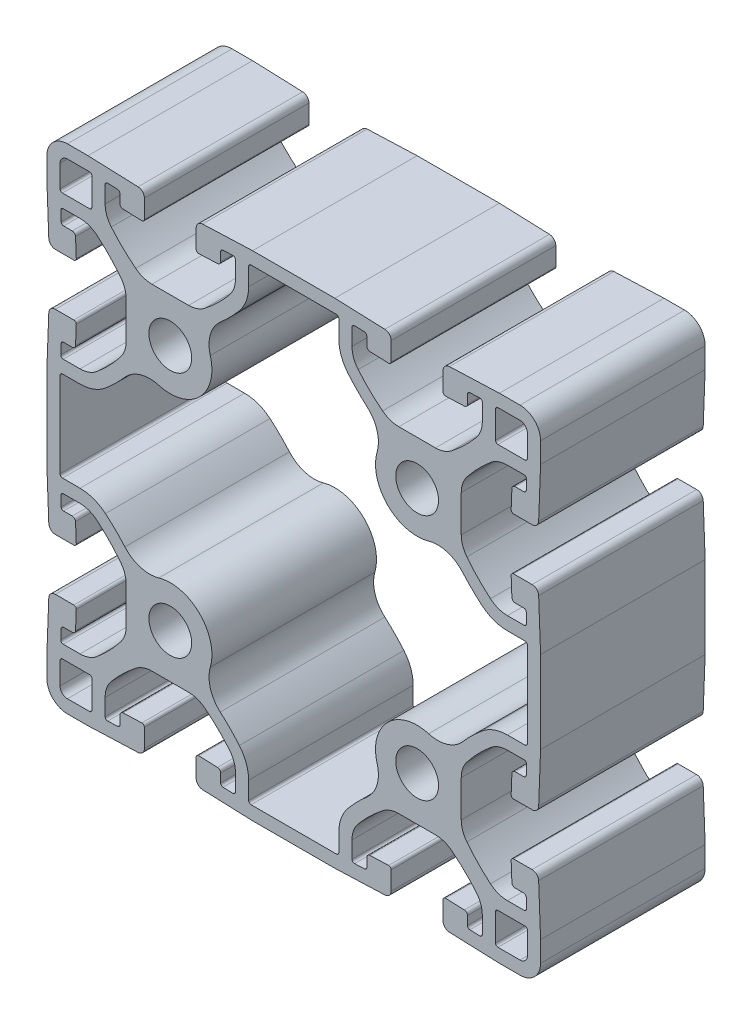
from build123d import *

# Parameters (mm, degrees)
SKETCH1_R      = 3.302
EXTRUDE1_DEPTH = 25.4


with BuildPart() as part:
    # Sketch1 → Extrude1 (new body)
    with BuildSketch(Plane.XY):
        with BuildLine():
            Line((44.9072, 40.928100791), (44.9072, 35.271899209))
            ThreePointArc((44.9072, 35.271899209), (45.129801128, 33.945343253), (45.773219048, 32.764108582))
            ThreePointArc((45.773219048, 32.764108582), (47.497406099, 30.785158596), (49.416608824, 28.994704762))
            ThreePointArc((49.416608824, 28.994704762), (50.63999053, 28.287303636), (52.031647412, 28.0416))
            Line((52.031647412, 28.0416), (54.619103526, 28.0416))
            ThreePointArc((54.619103526, 28.0416), (54.8936335, 28.158413903), (54.999822697, 28.437225755))
            Line((54.999822697, 28.437225755), (54.941276523, 29.961225755))
            ThreePointArc((54.941276523, 29.961225755), (54.824743448, 30.221129974), (54.560557352, 30.3276))
            Line((54.560557352, 30.3276), (53.230049894, 30.3276))
            ThreePointArc((53.230049894, 30.3276), (52.877801765, 30.469560035), (52.722424332, 30.816098993))
            Line((52.722424332, 30.816098993), (52.611487197, 33.703874245))
            ThreePointArc((52.611487197, 33.703874245), (52.717676395, 33.982686097), (52.992206369, 34.0995))
            Line((52.992206369, 34.0995), (55.838080274, 34.0995))
            ThreePointArc((55.838080274, 34.0995), (56.542576532, 33.815579929), (56.853331397, 33.122502014))
            Line((56.853331397, 33.122502014), (57.15, 25.4))
            Line((57.15, 25.4), (57.15, 19.05))
            Line((57.15, 19.05), (57.15, 12.7))
            Line((57.15, 12.7), (56.853331397, 4.977497986))
            ThreePointArc((56.853331397, 4.977497986), (56.542576532, 4.284420071), (55.838080274, 4.0005))
            Line((55.838080274, 4.0005), (52.992206369, 4.0005))
            ThreePointArc((52.992206369, 4.0005), (52.717676395, 4.117313903), (52.611487197, 4.396125755))
            Line((52.611487197, 4.396125755), (52.722424332, 7.283901007))
            ThreePointArc((52.722424332, 7.283901007), (52.877801765, 7.630439965), (53.230049894, 7.7724))
            Line((53.230049894, 7.7724), (54.560557352, 7.7724))
            ThreePointArc((54.560557352, 7.7724), (54.824743448, 7.878870026), (54.941276523, 8.138774245))
            Line((54.941276523, 8.138774245), (54.999822697, 9.662774245))
            ThreePointArc((54.999822697, 9.662774245), (54.8936335, 9.941586097), (54.619103526, 10.0584))
            Line((54.619103526, 10.0584), (52.031647412, 10.0584))
            ThreePointArc((52.031647412, 10.0584), (50.63999053, 9.812696364), (49.416608824, 9.105295238))
            ThreePointArc((49.416608824, 9.105295238), (47.497406099, 7.314841404), (45.773219048, 5.335891418))
            ThreePointArc((45.773219048, 5.335891418), (45.129801128, 4.154656747), (44.9072, 2.828100791))
            Line((44.9072, 2.828100791), (44.9072, -2.828100791))
            ThreePointArc((44.9072, -2.828100791), (45.129801128, -4.154656747), (45.773219048, -5.335891418))
            ThreePointArc((45.773219048, -5.335891418), (47.497406099, -7.314841404), (49.416608824, -9.105295238))
            ThreePointArc((49.416608824, -9.105295238), (50.63999053, -9.812696364), (52.031647412, -10.0584))
            Line((52.031647412, -10.0584), (54.619103526, -10.0584))
            ThreePointArc((54.619103526, -10.0584), (54.8936335, -9.941586097), (54.999822697, -9.662774245))
            Line((54.999822697, -9.662774245), (54.941276523, -8.138774245))
            ThreePointArc((54.941276523, -8.138774245), (54.824743448, -7.878870026), (54.560557352, -7.7724))
            Line((54.560557352, -7.7724), (53.230049894, -7.7724))
            ThreePointArc((53.230049894, -7.7724), (52.877801765, -7.630439965), (52.722424332, -7.283901007))
            Line((52.722424332, -7.283901007), (52.611487197, -4.396125755))
            ThreePointArc((52.611487197, -4.396125755), (52.717676395, -4.117313903), (52.992206369, -4.0005))
            Line((52.992206369, -4.0005), (55.838080274, -4.0005))
            ThreePointArc((55.838080274, -4.0005), (56.542576532, -4.284420071), (56.853331397, -4.977497986))
            Line((56.853331397, -4.977497986), (57.15, -12.7))
            Line((57.15, -12.7), (57.15, -15.875))
            ThreePointArc((57.15, -15.875), (56.22006403, -18.12006403), (53.975, -19.05))
            Line((53.975, -19.05), (50.8, -19.05))
            Line((50.8, -19.05), (43.077497986, -18.753331397))
            ThreePointArc((43.077497986, -18.753331397), (42.384420071, -18.442576532), (42.1005, -17.738080274))
            Line((42.1005, -17.738080274), (42.1005, -14.892206369))
            ThreePointArc((42.1005, -14.892206369), (42.217313903, -14.617676395), (42.496125755, -14.511487197))
            Line((42.496125755, -14.511487197), (45.383901007, -14.622424332))
            ThreePointArc((45.383901007, -14.622424332), (45.730439965, -14.777801765), (45.8724, -15.130049894))
            Line((45.8724, -15.130049894), (45.8724, -16.460557352))
            ThreePointArc((45.8724, -16.460557352), (45.978870026, -16.724743448), (46.238774245, -16.841276523))
            Line((46.238774245, -16.841276523), (47.762774245, -16.899822697))
            ThreePointArc((47.762774245, -16.899822697), (48.041586097, -16.7936335), (48.1584, -16.519103526))
            Line((48.1584, -16.519103526), (48.1584, -13.931647412))
            ThreePointArc((48.1584, -13.931647412), (47.912696364, -12.53999053), (47.205295238, -11.316608824))
            ThreePointArc((47.205295238, -11.316608824), (45.414841404, -9.397406099), (43.435891418, -7.673219048))
            ThreePointArc((43.435891418, -7.673219048), (42.254656747, -7.029801128), (40.928100791, -6.8072))
            Line((40.928100791, -6.8072), (35.271899209, -6.8072))
            ThreePointArc((35.271899209, -6.8072), (33.945343253, -7.029801128), (32.764108582, -7.673219048))
            ThreePointArc((32.764108582, -7.673219048), (30.785158596, -9.397406099), (28.994704762, -11.316608824))
            ThreePointArc((28.994704762, -11.316608824), (28.287303636, -12.53999053), (28.0416, -13.931647412))
            Line((28.0416, -13.931647412), (28.0416, -16.519103526))
            ThreePointArc((28.0416, -16.519103526), (28.158413903, -16.7936335), (28.437225755, -16.899822697))
            Line((28.437225755, -16.899822697), (29.961225755, -16.841276523))
            ThreePointArc((29.961225755, -16.841276523), (30.221129974, -16.724743448), (30.3276, -16.460557352))
            Line((30.3276, -16.460557352), (30.3276, -15.130049894))
            ThreePointArc((30.3276, -15.130049894), (30.469560035, -14.777801765), (30.816098993, -14.622424332))
            Line((30.816098993, -14.622424332), (33.703874245, -14.511487197))
            ThreePointArc((33.703874245, -14.511487197), (33.982686097, -14.617676395), (34.0995, -14.892206369))
            Line((34.0995, -14.892206369), (34.0995, -17.738080274))
            ThreePointArc((34.0995, -17.738080274), (33.815579929, -18.442576532), (33.122502014, -18.753331397))
            Line((33.122502014, -18.753331397), (25.4, -19.05))
            Line((25.4, -19.05), (19.05, -19.05))
            Line((19.05, -19.05), (12.7, -19.05))
            Line((12.7, -19.05), (4.977497986, -18.753331397))
            ThreePointArc((4.977497986, -18.753331397), (4.284420071, -18.442576532), (4.0005, -17.738080274))
            Line((4.0005, -17.738080274), (4.0005, -14.892206369))
            ThreePointArc((4.0005, -14.892206369), (4.117313903, -14.617676395), (4.396125755, -14.511487197))
            Line((4.396125755, -14.511487197), (7.283901007, -14.622424332))
            ThreePointArc((7.283901007, -14.622424332), (7.630439965, -14.777801765), (7.7724, -15.130049894))
            Line((7.7724, -15.130049894), (7.7724, -16.460557352))
            ThreePointArc((7.7724, -16.460557352), (7.878870026, -16.724743448), (8.138774245, -16.841276523))
            Line((8.138774245, -16.841276523), (9.662774245, -16.899822697))
            ThreePointArc((9.662774245, -16.899822697), (9.941586097, -16.7936335), (10.0584, -16.519103526))
            Line((10.0584, -16.519103526), (10.0584, -13.931647412))
            ThreePointArc((10.0584, -13.931647412), (9.812696364, -12.53999053), (9.105295238, -11.316608824))
            ThreePointArc((9.105295238, -11.316608824), (7.314841404, -9.397406099), (5.335891418, -7.673219048))
            ThreePointArc((5.335891418, -7.673219048), (4.154656747, -7.029801128), (2.828100791, -6.8072))
            Line((2.828100791, -6.8072), (-2.828100791, -6.8072))
            ThreePointArc((-2.828100791, -6.8072), (-4.154656747, -7.029801128), (-5.335891418, -7.673219048))
            ThreePointArc((-5.335891418, -7.673219048), (-7.314841404, -9.397406099), (-9.105295238, -11.316608824))
            ThreePointArc((-9.105295238, -11.316608824), (-9.812696364, -12.53999053), (-10.0584, -13.931647412))
            Line((-10.0584, -13.931647412), (-10.0584, -16.519103526))
            ThreePointArc((-10.0584, -16.519103526), (-9.941586097, -16.7936335), (-9.662774245, -16.899822697))
            Line((-9.662774245, -16.899822697), (-8.138774245, -16.841276523))
            ThreePointArc((-8.138774245, -16.841276523), (-7.878870026, -16.724743448), (-7.7724, -16.460557352))
            Line((-7.7724, -16.460557352), (-7.7724, -15.130049894))
            ThreePointArc((-7.7724, -15.130049894), (-7.630439965, -14.777801765), (-7.283901007, -14.622424332))
            Line((-7.283901007, -14.622424332), (-4.396125755, -14.511487197))
            ThreePointArc((-4.396125755, -14.511487197), (-4.117313903, -14.617676395), (-4.0005, -14.892206369))
            Line((-4.0005, -14.892206369), (-4.0005, -17.738080274))
            ThreePointArc((-4.0005, -17.738080274), (-4.284420071, -18.442576532), (-4.977497986, -18.753331397))
            Line((-4.977497986, -18.753331397), (-12.7, -19.05))
            Line((-12.7, -19.05), (-15.875, -19.05))
            ThreePointArc((-15.875, -19.05), (-18.12006403, -18.12006403), (-19.05, -15.875))
            Line((-19.05, -15.875), (-19.05, -12.7))
            Line((-19.05, -12.7), (-18.753331397, -4.977497986))
            ThreePointArc((-18.753331397, -4.977497986), (-18.442576532, -4.284420071), (-17.738080274, -4.0005))
            Line((-17.738080274, -4.0005), (-14.892206369, -4.0005))
            ThreePointArc((-14.892206369, -4.0005), (-14.617676395, -4.117313903), (-14.511487197, -4.396125755))
            Line((-14.511487197, -4.396125755), (-14.622424332, -7.283901007))
            ThreePointArc((-14.622424332, -7.283901007), (-14.777801765, -7.630439965), (-15.130049894, -7.7724))
            Line((-15.130049894, -7.7724), (-16.460557352, -7.7724))
            ThreePointArc((-16.460557352, -7.7724), (-16.724743448, -7.878870026), (-16.841276523, -8.138774245))
            Line((-16.841276523, -8.138774245), (-16.899822697, -9.662774245))
            ThreePointArc((-16.899822697, -9.662774245), (-16.7936335, -9.941586097), (-16.519103526, -10.0584))
            Line((-16.519103526, -10.0584), (-13.931647412, -10.0584))
            ThreePointArc((-13.931647412, -10.0584), (-12.53999053, -9.812696364), (-11.316608824, -9.105295238))
            ThreePointArc((-11.316608824, -9.105295238), (-9.397406099, -7.314841404), (-7.673219048, -5.335891418))
            ThreePointArc((-7.673219048, -5.335891418), (-7.029801128, -4.154656747), (-6.8072, -2.828100791))
            Line((-6.8072, -2.828100791), (-6.8072, 2.828100791))
            ThreePointArc((-6.8072, 2.828100791), (-7.029801128, 4.154656747), (-7.673219048, 5.335891418))
            ThreePointArc((-7.673219048, 5.335891418), (-9.397406099, 7.314841404), (-11.316608824, 9.105295238))
            ThreePointArc((-11.316608824, 9.105295238), (-12.53999053, 9.812696364), (-13.931647412, 10.0584))
            Line((-13.931647412, 10.0584), (-16.519103526, 10.0584))
            ThreePointArc((-16.519103526, 10.0584), (-16.7936335, 9.941586097), (-16.899822697, 9.662774245))
            Line((-16.899822697, 9.662774245), (-16.841276523, 8.138774245))
            ThreePointArc((-16.841276523, 8.138774245), (-16.724743448, 7.878870026), (-16.460557352, 7.7724))
            Line((-16.460557352, 7.7724), (-15.130049894, 7.7724))
            ThreePointArc((-15.130049894, 7.7724), (-14.777801765, 7.630439965), (-14.622424332, 7.283901007))
            Line((-14.622424332, 7.283901007), (-14.511487197, 4.396125755))
            ThreePointArc((-14.511487197, 4.396125755), (-14.617676395, 4.117313903), (-14.892206369, 4.0005))
            Line((-14.892206369, 4.0005), (-17.738080274, 4.0005))
            ThreePointArc((-17.738080274, 4.0005), (-18.442576532, 4.284420071), (-18.753331397, 4.977497986))
            Line((-18.753331397, 4.977497986), (-19.05, 12.7))
            Line((-19.05, 12.7), (-19.05, 19.05))
            Line((-19.05, 19.05), (-19.05, 25.4))
            Line((-19.05, 25.4), (-18.753331397, 33.122502014))
            ThreePointArc((-18.753331397, 33.122502014), (-18.442576532, 33.815579929), (-17.738080274, 34.0995))
            Line((-17.738080274, 34.0995), (-14.892206369, 34.0995))
            ThreePointArc((-14.892206369, 34.0995), (-14.617676395, 33.982686097), (-14.511487197, 33.703874245))
            Line((-14.511487197, 33.703874245), (-14.622424332, 30.816098993))
            ThreePointArc((-14.622424332, 30.816098993), (-14.777801765, 30.469560035), (-15.130049894, 30.3276))
            Line((-15.130049894, 30.3276), (-16.460557352, 30.3276))
            ThreePointArc((-16.460557352, 30.3276), (-16.724743448, 30.221129974), (-16.841276523, 29.961225755))
            Line((-16.841276523, 29.961225755), (-16.899822697, 28.437225755))
            ThreePointArc((-16.899822697, 28.437225755), (-16.7936335, 28.158413903), (-16.519103526, 28.0416))
            Line((-16.519103526, 28.0416), (-13.931647412, 28.0416))
            ThreePointArc((-13.931647412, 28.0416), (-12.53999053, 28.287303636), (-11.316608824, 28.994704762))
            ThreePointArc((-11.316608824, 28.994704762), (-9.397406099, 30.785158596), (-7.673219048, 32.764108582))
            ThreePointArc((-7.673219048, 32.764108582), (-7.029801128, 33.945343253), (-6.8072, 35.271899209))
            Line((-6.8072, 35.271899209), (-6.8072, 40.928100791))
            ThreePointArc((-6.8072, 40.928100791), (-7.029801128, 42.254656747), (-7.673219048, 43.435891418))
            ThreePointArc((-7.673219048, 43.435891418), (-9.397406099, 45.414841404), (-11.316608824, 47.205295238))
            ThreePointArc((-11.316608824, 47.205295238), (-12.53999053, 47.912696364), (-13.931647412, 48.1584))
            Line((-13.931647412, 48.1584), (-16.519103526, 48.1584))
            ThreePointArc((-16.519103526, 48.1584), (-16.7936335, 48.041586097), (-16.899822697, 47.762774245))
            Line((-16.899822697, 47.762774245), (-16.841276523, 46.238774245))
            ThreePointArc((-16.841276523, 46.238774245), (-16.724743448, 45.978870026), (-16.460557352, 45.8724))
            Line((-16.460557352, 45.8724), (-15.130049894, 45.8724))
            ThreePointArc((-15.130049894, 45.8724), (-14.777801765, 45.730439965), (-14.622424332, 45.383901007))
            Line((-14.622424332, 45.383901007), (-14.511487197, 42.496125755))
            ThreePointArc((-14.511487197, 42.496125755), (-14.617676395, 42.217313903), (-14.892206369, 42.1005))
            Line((-14.892206369, 42.1005), (-17.738080274, 42.1005))
            ThreePointArc((-17.738080274, 42.1005), (-18.442576532, 42.384420071), (-18.753331397, 43.077497986))
            Line((-18.753331397, 43.077497986), (-19.05, 50.8))
            Line((-19.05, 50.8), (-19.05, 53.975))
            ThreePointArc((-19.05, 53.975), (-18.12006403, 56.22006403), (-15.875, 57.15))
            Line((-15.875, 57.15), (-12.7, 57.15))
            Line((-12.7, 57.15), (-4.977497986, 56.853331397))
            ThreePointArc((-4.977497986, 56.853331397), (-4.284420071, 56.542576532), (-4.0005, 55.838080274))
            Line((-4.0005, 55.838080274), (-4.0005, 52.992206369))
            ThreePointArc((-4.0005, 52.992206369), (-4.117313903, 52.717676395), (-4.396125755, 52.611487197))
            Line((-4.396125755, 52.611487197), (-7.283901007, 52.722424332))
            ThreePointArc((-7.283901007, 52.722424332), (-7.630439965, 52.877801765), (-7.7724, 53.230049894))
            Line((-7.7724, 53.230049894), (-7.7724, 54.560557352))
            ThreePointArc((-7.7724, 54.560557352), (-7.878870026, 54.824743448), (-8.138774245, 54.941276523))
            Line((-8.138774245, 54.941276523), (-9.662774245, 54.999822697))
            ThreePointArc((-9.662774245, 54.999822697), (-9.941586097, 54.8936335), (-10.0584, 54.619103526))
            Line((-10.0584, 54.619103526), (-10.0584, 52.031647412))
            ThreePointArc((-10.0584, 52.031647412), (-9.812696364, 50.63999053), (-9.105295238, 49.416608824))
            ThreePointArc((-9.105295238, 49.416608824), (-7.314841404, 47.497406099), (-5.335891418, 45.773219048))
            ThreePointArc((-5.335891418, 45.773219048), (-4.154656747, 45.129801128), (-2.828100791, 44.9072))
            Line((-2.828100791, 44.9072), (2.828100791, 44.9072))
            ThreePointArc((2.828100791, 44.9072), (4.154656747, 45.129801128), (5.335891418, 45.773219048))
            ThreePointArc((5.335891418, 45.773219048), (7.314841404, 47.497406099), (9.105295238, 49.416608824))
            ThreePointArc((9.105295238, 49.416608824), (9.812696364, 50.63999053), (10.0584, 52.031647412))
            Line((10.0584, 52.031647412), (10.0584, 54.619103526))
            ThreePointArc((10.0584, 54.619103526), (9.941586097, 54.8936335), (9.662774245, 54.999822697))
            Line((9.662774245, 54.999822697), (8.138774245, 54.941276523))
            ThreePointArc((8.138774245, 54.941276523), (7.878870026, 54.824743448), (7.7724, 54.560557352))
            Line((7.7724, 54.560557352), (7.7724, 53.230049894))
            ThreePointArc((7.7724, 53.230049894), (7.630439965, 52.877801765), (7.283901007, 52.722424332))
            Line((7.283901007, 52.722424332), (4.396125755, 52.611487197))
            ThreePointArc((4.396125755, 52.611487197), (4.117313903, 52.717676395), (4.0005, 52.992206369))
            Line((4.0005, 52.992206369), (4.0005, 55.838080274))
            ThreePointArc((4.0005, 55.838080274), (4.284420071, 56.542576532), (4.977497986, 56.853331397))
            Line((4.977497986, 56.853331397), (12.7, 57.15))
            Line((12.7, 57.15), (19.05, 57.15))
            Line((19.05, 57.15), (25.4, 57.15))
            Line((25.4, 57.15), (33.122502014, 56.853331397))
            ThreePointArc((33.122502014, 56.853331397), (33.815579929, 56.542576532), (34.0995, 55.838080274))
            Line((34.0995, 55.838080274), (34.0995, 52.992206369))
            ThreePointArc((34.0995, 52.992206369), (33.982686097, 52.717676395), (33.703874245, 52.611487197))
            Line((33.703874245, 52.611487197), (30.816098993, 52.722424332))
            ThreePointArc((30.816098993, 52.722424332), (30.469560035, 52.877801765), (30.3276, 53.230049894))
            Line((30.3276, 53.230049894), (30.3276, 54.560557352))
            ThreePointArc((30.3276, 54.560557352), (30.221129974, 54.824743448), (29.961225755, 54.941276523))
            Line((29.961225755, 54.941276523), (28.437225755, 54.999822697))
            ThreePointArc((28.437225755, 54.999822697), (28.158413903, 54.8936335), (28.0416, 54.619103526))
            Line((28.0416, 54.619103526), (28.0416, 52.031647412))
            ThreePointArc((28.0416, 52.031647412), (28.287303636, 50.63999053), (28.994704762, 49.416608824))
            ThreePointArc((28.994704762, 49.416608824), (30.785158596, 47.497406099), (32.764108582, 45.773219048))
            ThreePointArc((32.764108582, 45.773219048), (33.945343253, 45.129801128), (35.271899209, 44.9072))
            Line((35.271899209, 44.9072), (40.928100791, 44.9072))
            ThreePointArc((40.928100791, 44.9072), (42.254656747, 45.129801128), (43.435891418, 45.773219048))
            ThreePointArc((43.435891418, 45.773219048), (45.414841404, 47.497406099), (47.205295238, 49.416608824))
            ThreePointArc((47.205295238, 49.416608824), (47.912696364, 50.63999053), (48.1584, 52.031647412))
            Line((48.1584, 52.031647412), (48.1584, 54.619103526))
            ThreePointArc((48.1584, 54.619103526), (48.041586097, 54.8936335), (47.762774245, 54.999822697))
            Line((47.762774245, 54.999822697), (46.238774245, 54.941276523))
            ThreePointArc((46.238774245, 54.941276523), (45.978870026, 54.824743448), (45.8724, 54.560557352))
            Line((45.8724, 54.560557352), (45.8724, 53.230049894))
            ThreePointArc((45.8724, 53.230049894), (45.730439965, 52.877801765), (45.383901007, 52.722424332))
            Line((45.383901007, 52.722424332), (42.496125755, 52.611487197))
            ThreePointArc((42.496125755, 52.611487197), (42.217313903, 52.717676395), (42.1005, 52.992206369))
            Line((42.1005, 52.992206369), (42.1005, 55.838080274))
            ThreePointArc((42.1005, 55.838080274), (42.384420071, 56.542576532), (43.077497986, 56.853331397))
            Line((43.077497986, 56.853331397), (50.8, 57.15))
            Line((50.8, 57.15), (53.975, 57.15))
            ThreePointArc((53.975, 57.15), (56.22006403, 56.22006403), (57.15, 53.975))
            Line((57.15, 53.975), (57.15, 50.8))
            Line((57.15, 50.8), (56.853331397, 43.077497986))
            ThreePointArc((56.853331397, 43.077497986), (56.542576532, 42.384420071), (55.838080274, 42.1005))
            Line((55.838080274, 42.1005), (52.992206369, 42.1005))
            ThreePointArc((52.992206369, 42.1005), (52.717676395, 42.217313903), (52.611487197, 42.496125755))
            Line((52.611487197, 42.496125755), (52.722424332, 45.383901007))
            ThreePointArc((52.722424332, 45.383901007), (52.877801765, 45.730439965), (53.230049894, 45.8724))
            Line((53.230049894, 45.8724), (54.560557352, 45.8724))
            ThreePointArc((54.560557352, 45.8724), (54.824743448, 45.978870026), (54.941276523, 46.238774245))
            Line((54.941276523, 46.238774245), (54.999822697, 47.762774245))
            ThreePointArc((54.999822697, 47.762774245), (54.8936335, 48.041586097), (54.619103526, 48.1584))
            Line((54.619103526, 48.1584), (52.031647412, 48.1584))
            ThreePointArc((52.031647412, 48.1584), (50.63999053, 47.912696364), (49.416608824, 47.205295238))
            ThreePointArc((49.416608824, 47.205295238), (47.497406099, 45.414841404), (45.773219048, 43.435891418))
            ThreePointArc((45.773219048, 43.435891418), (45.129801128, 42.254656747), (44.9072, 40.928100791))
        make_face()
        Circle(SKETCH1_R, mode=Mode.SUBTRACT)
        with Locations((0, 38.1)):
            Circle(SKETCH1_R, mode=Mode.SUBTRACT)
        with Locations((38.1, 0)):
            Circle(SKETCH1_R, mode=Mode.SUBTRACT)
        with Locations((38.1, 38.1)):
            Circle(SKETCH1_R, mode=Mode.SUBTRACT)
        with BuildLine():
            Line((26.0096, 54.737), (26.0096, 52.031647412))
            ThreePointArc((26.0096, 52.031647412), (26.378155454, 49.94416209), (27.439257143, 48.10908953))
            ThreePointArc((27.439257143, 48.10908953), (28.854602939, 46.550888476), (30.385264699, 45.105804111))
            ThreePointArc((30.385264699, 45.105804111), (31.915543143, 42.71504971), (31.924232361, 39.876496695))
            ThreePointArc((31.924232361, 39.876496695), (33.555990403, 33.555990403), (39.876496695, 31.924232361))
            ThreePointArc((39.876496695, 31.924232361), (42.71504971, 31.915543143), (45.105804111, 30.385264699))
            ThreePointArc((45.105804111, 30.385264699), (46.550888476, 28.854602939), (48.10908953, 27.439257143))
            ThreePointArc((48.10908953, 27.439257143), (49.94416209, 26.378155454), (52.031647412, 26.0096))
            Line((52.031647412, 26.0096), (54.737, 26.0096))
            ThreePointArc((54.737, 26.0096), (55.006407684, 25.898007684), (55.118, 25.6286))
            Line((55.118, 25.6286), (55.118, 19.05))
            Line((55.118, 19.05), (55.118, 12.4714))
            ThreePointArc((55.118, 12.4714), (55.006407684, 12.201992316), (54.737, 12.0904))
            Line((54.737, 12.0904), (52.031647412, 12.0904))
            ThreePointArc((52.031647412, 12.0904), (49.94416209, 11.721844546), (48.10908953, 10.660742857))
            ThreePointArc((48.10908953, 10.660742857), (46.550888476, 9.245397061), (45.105804111, 7.714735301))
            ThreePointArc((45.105804111, 7.714735301), (42.71504971, 6.184456857), (39.876496695, 6.175767639))
            ThreePointArc((39.876496695, 6.175767639), (33.555990403, 4.544009597), (31.924232361, -1.776496695))
            ThreePointArc((31.924232361, -1.776496695), (31.915543143, -4.61504971), (30.385264699, -7.005804111))
            ThreePointArc((30.385264699, -7.005804111), (28.854602939, -8.450888476), (27.439257143, -10.00908953))
            ThreePointArc((27.439257143, -10.00908953), (26.378155454, -11.84416209), (26.0096, -13.931647412))
            Line((26.0096, -13.931647412), (26.0096, -16.637))
            ThreePointArc((26.0096, -16.637), (25.898007684, -16.906407684), (25.6286, -17.018))
            Line((25.6286, -17.018), (19.05, -17.018))
            Line((19.05, -17.018), (12.4714, -17.018))
            ThreePointArc((12.4714, -17.018), (12.201992316, -16.906407684), (12.0904, -16.637))
            Line((12.0904, -16.637), (12.0904, -13.931647412))
            ThreePointArc((12.0904, -13.931647412), (11.721844546, -11.84416209), (10.660742857, -10.00908953))
            ThreePointArc((10.660742857, -10.00908953), (9.245397061, -8.450888476), (7.714735301, -7.005804111))
            ThreePointArc((7.714735301, -7.005804111), (6.184456857, -4.61504971), (6.175767639, -1.776496695))
            ThreePointArc((6.175767639, -1.776496695), (4.544009597, 4.544009597), (-1.776496695, 6.175767639))
            ThreePointArc((-1.776496695, 6.175767639), (-4.61504971, 6.184456857), (-7.005804111, 7.714735301))
            ThreePointArc((-7.005804111, 7.714735301), (-8.450888476, 9.245397061), (-10.00908953, 10.660742857))
            ThreePointArc((-10.00908953, 10.660742857), (-11.84416209, 11.721844546), (-13.931647412, 12.0904))
            Line((-13.931647412, 12.0904), (-16.637, 12.0904))
            ThreePointArc((-16.637, 12.0904), (-16.906407684, 12.201992316), (-17.018, 12.4714))
            Line((-17.018, 12.4714), (-17.018, 19.05))
            Line((-17.018, 19.05), (-17.018, 25.6286))
            ThreePointArc((-17.018, 25.6286), (-16.906407684, 25.898007684), (-16.637, 26.0096))
            Line((-16.637, 26.0096), (-13.931647412, 26.0096))
            ThreePointArc((-13.931647412, 26.0096), (-11.84416209, 26.378155454), (-10.00908953, 27.439257143))
            ThreePointArc((-10.00908953, 27.439257143), (-8.450888476, 28.854602939), (-7.005804111, 30.385264699))
            ThreePointArc((-7.005804111, 30.385264699), (-4.61504971, 31.915543143), (-1.776496695, 31.924232361))
            ThreePointArc((-1.776496695, 31.924232361), (4.544009597, 33.555990403), (6.175767639, 39.876496695))
            ThreePointArc((6.175767639, 39.876496695), (6.184456857, 42.71504971), (7.714735301, 45.105804111))
            ThreePointArc((7.714735301, 45.105804111), (9.245397061, 46.550888476), (10.660742857, 48.10908953))
            ThreePointArc((10.660742857, 48.10908953), (11.721844546, 49.94416209), (12.0904, 52.031647412))
            Line((12.0904, 52.031647412), (12.0904, 54.737))
            ThreePointArc((12.0904, 54.737), (12.201992316, 55.006407684), (12.4714, 55.118))
            Line((12.4714, 55.118), (19.05, 55.118))
            Line((19.05, 55.118), (25.6286, 55.118))
            ThreePointArc((25.6286, 55.118), (25.898007684, 55.006407684), (26.0096, 54.737))
        make_face(mode=Mode.SUBTRACT)
        with BuildLine():
            Line((-17.018, -12.4714), (-17.018, -15.875))
            ThreePointArc((-17.018, -15.875), (-16.683223051, -16.683223051), (-15.875, -17.018))
            Line((-15.875, -17.018), (-12.4714, -17.018))
            ThreePointArc((-12.4714, -17.018), (-12.201992316, -16.906407684), (-12.0904, -16.637))
            Line((-12.0904, -16.637), (-12.0904, -12.4714))
            ThreePointArc((-12.0904, -12.4714), (-12.201992316, -12.201992316), (-12.4714, -12.0904))
            Line((-12.4714, -12.0904), (-16.637, -12.0904))
            ThreePointArc((-16.637, -12.0904), (-16.906407684, -12.201992316), (-17.018, -12.4714))
        make_face(mode=Mode.SUBTRACT)
        with BuildLine():
            Line((54.737, -12.0904), (50.5714, -12.0904))
            ThreePointArc((50.5714, -12.0904), (50.301992316, -12.201992316), (50.1904, -12.4714))
            Line((50.1904, -12.4714), (50.1904, -16.637))
            ThreePointArc((50.1904, -16.637), (50.301992316, -16.906407684), (50.5714, -17.018))
            Line((50.5714, -17.018), (53.975, -17.018))
            ThreePointArc((53.975, -17.018), (54.783223051, -16.683223051), (55.118, -15.875))
            Line((55.118, -15.875), (55.118, -12.4714))
            ThreePointArc((55.118, -12.4714), (55.006407684, -12.201992316), (54.737, -12.0904))
        make_face(mode=Mode.SUBTRACT)
        with BuildLine():
            Line((-12.0904, 54.737), (-12.0904, 50.5714))
            ThreePointArc((-12.0904, 50.5714), (-12.201992316, 50.301992316), (-12.4714, 50.1904))
            Line((-12.4714, 50.1904), (-16.637, 50.1904))
            ThreePointArc((-16.637, 50.1904), (-16.906407684, 50.301992316), (-17.018, 50.5714))
            Line((-17.018, 50.5714), (-17.018, 53.975))
            ThreePointArc((-17.018, 53.975), (-16.683223051, 54.783223051), (-15.875, 55.118))
            Line((-15.875, 55.118), (-12.4714, 55.118))
            ThreePointArc((-12.4714, 55.118), (-12.201992316, 55.006407684), (-12.0904, 54.737))
        make_face(mode=Mode.SUBTRACT)
        with BuildLine():
            Line((55.118, 50.5714), (55.118, 53.975))
            ThreePointArc((55.118, 53.975), (54.783223051, 54.783223051), (53.975, 55.118))
            Line((53.975, 55.118), (50.5714, 55.118))
            ThreePointArc((50.5714, 55.118), (50.301992316, 55.006407684), (50.1904, 54.737))
            Line((50.1904, 54.737), (50.1904, 50.5714))
            ThreePointArc((50.1904, 50.5714), (50.301992316, 50.301992316), (50.5714, 50.1904))
            Line((50.5714, 50.1904), (54.737, 50.1904))
            ThreePointArc((54.737, 50.1904), (55.006407684, 50.301992316), (55.118, 50.5714))
        make_face(mode=Mode.SUBTRACT)
    extrude(amount=EXTRUDE1_DEPTH)


solid = part.part
